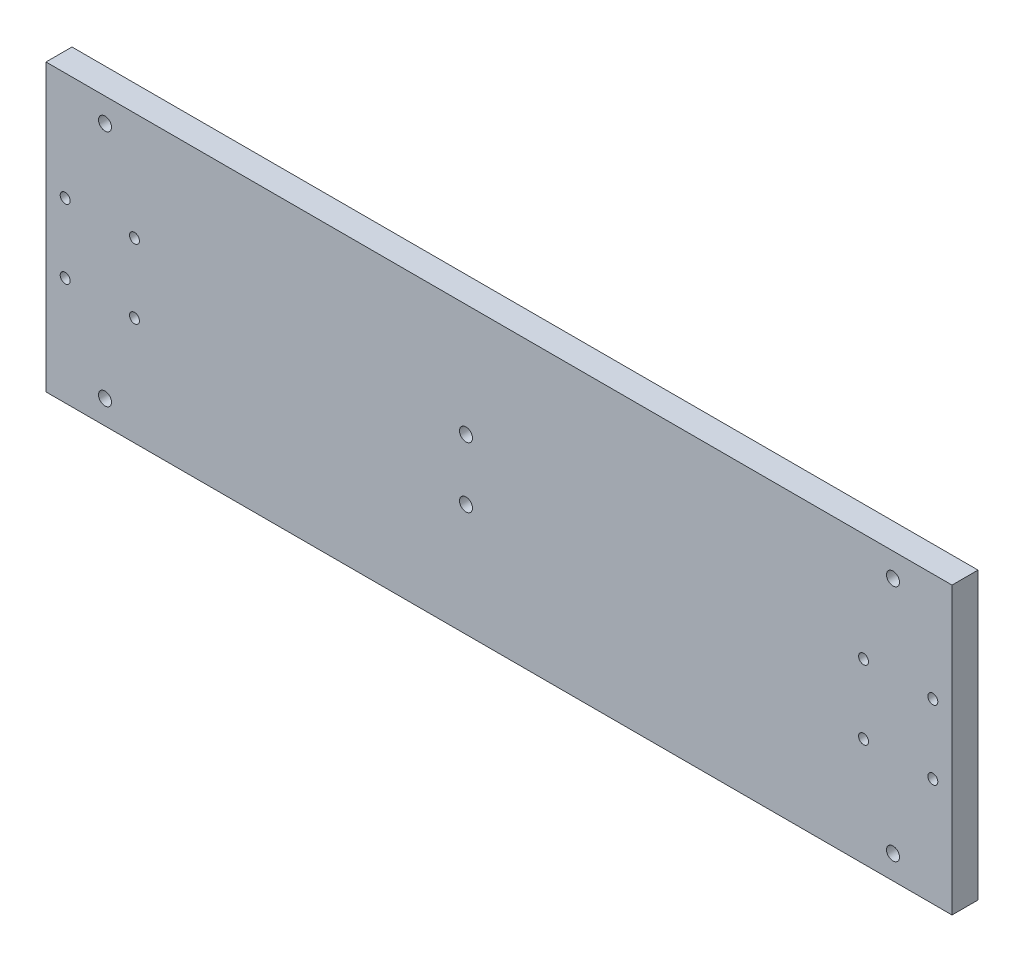
from build123d import *

# Parameters (mm, degrees)
ESQUISSE1_W             = 209.26
ESQUISSE1_H             = 66
BOSS_EXTRU_1_DEPTH      = 6
ESQUISSE2_R             = 1.15
ESQUISSE2_R_2           = 1.5
ENL_V_MAT_EXTRU_1_DEPTH = 6


with BuildPart() as part:
    # Esquisse1 → Boss.-Extru.1 (new body)
    with BuildSketch(Plane.XY):
        Rectangle(ESQUISSE1_W, ESQUISSE1_H)
    extrude(amount=BOSS_EXTRU_1_DEPTH)

    # Esquisse2 → Enlèv. mat.-Extru.1 (cut)
    with BuildSketch(Plane.XY.offset(6)):
        with Locations((-100.2, 8)):
            Circle(ESQUISSE2_R)
        with Locations((-84.2, 8)):
            Circle(ESQUISSE2_R)
        with Locations((-84.2, -8)):
            Circle(ESQUISSE2_R)
        with Locations((-100.2, -8)):
            Circle(ESQUISSE2_R)
        with Locations((100.2, -8)):
            Circle(ESQUISSE2_R)
        with Locations((84.2, -8)):
            Circle(ESQUISSE2_R)
        with Locations((84.2, 8)):
            Circle(ESQUISSE2_R)
        with Locations((100.2, 8)):
            Circle(ESQUISSE2_R)
        with Locations((-7.625, 7)):
            Circle(ESQUISSE2_R_2)
        with Locations((-7.625, -7)):
            Circle(ESQUISSE2_R_2)
        with Locations((91, 27.5)):
            Circle(ESQUISSE2_R_2)
        with Locations((91, -27.5)):
            Circle(ESQUISSE2_R_2)
        with Locations((-91, -27.5)):
            Circle(ESQUISSE2_R_2)
        with Locations((-91, 27.5)):
            Circle(ESQUISSE2_R_2)
    extrude(amount=-ENL_V_MAT_EXTRU_1_DEPTH, mode=Mode.SUBTRACT)


solid = part.part
